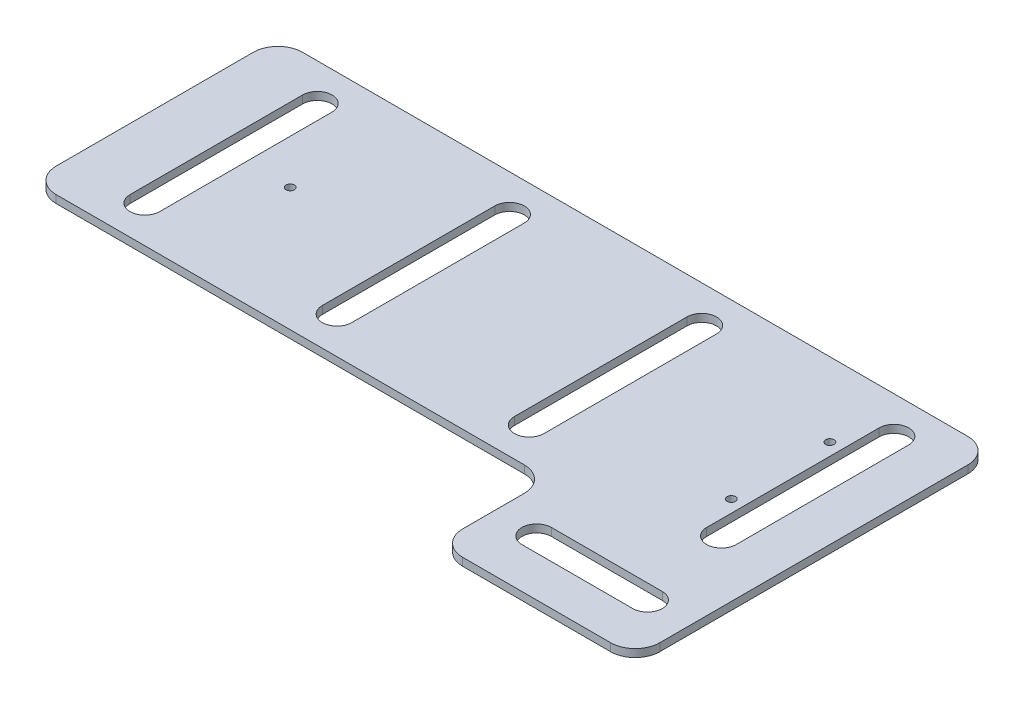
from build123d import *

# Parameters (mm, degrees)
BOSS_EXTRUDE1_DEPTH = 3.175
FILLET1_R           = 10
STANDOFF_HOLES_D    = 3.4
CUT_EXTRUDE1_DEPTH  = 3.175


with BuildPart() as part:
    # Sketch1 → Boss-Extrude1 (new body)
    with BuildSketch(Plane(origin=(0, 0, 0), x_dir=(1, 0, 0), z_dir=(0, 1, 0))):
        Polygon((-37.5, -50), (-145, -50), (-145, 50), (145, 50), (145, -50), (145, -95), (65, -95), (65, -50), (37.5, -50), align=None)
    extrude(amount=BOSS_EXTRUDE1_DEPTH)

    # Fillet1
    fillet1_edges = [part.edges().sort_by_distance(p)[0] for p in [
        (-145, 1.5875, 50),
        (-145, 1.5875, -50),
        (145, 1.5875, -50),
        (145, 1.5875, 95),
        (65, 1.5875, 95),
        (65, 1.5875, 50),
    ]]
    fillet(fillet1_edges, radius=FILLET1_R)

    # standoff holes (through all)
    with Locations(Plane(origin=(0, 3.175, 0), x_dir=(1, 0, 0), z_dir=(0, 1, 0))):
        with Locations((-90, 0), (109, 20), (109, -20)):
            Hole(STANDOFF_HOLES_D / 2)

    # Sketch6 → Cut-Extrude1 (cut)
    with BuildSketch(Plane(origin=(0, 3.175, 0), x_dir=(1, 0, 0), z_dir=(0, 1, 0))):
        with BuildLine():
            Line((-108, 35), (-108, -35))
            ThreePointArc((-108, -35), (-114, -41), (-120, -35))
            Line((-120, -35), (-120, 35))
            ThreePointArc((-120, 35), (-114, 41), (-108, 35))
        make_face()
        with BuildLine():
            Line((-30, 35), (-30, -35))
            ThreePointArc((-30, -35), (-36, -41), (-42, -35))
            Line((-42, -35), (-42, 35))
            ThreePointArc((-42, 35), (-36, 41), (-30, 35))
        make_face()
        with BuildLine():
            Line((48, 35), (48, -35))
            ThreePointArc((48, -35), (42, -41), (36, -35))
            Line((36, -35), (36, 35))
            ThreePointArc((36, 35), (42, 41), (48, 35))
        make_face()
        with BuildLine():
            Line((126, 35), (126, -35))
            ThreePointArc((126, -35), (120, -41), (114, -35))
            Line((114, -35), (114, 35))
            ThreePointArc((114, 35), (120, 41), (126, 35))
        make_face()
        with BuildLine():
            Line((82.5, -66.5), (127.5, -66.5))
            ThreePointArc((127.5, -66.5), (133.5, -72.5), (127.5, -78.5))
            Line((127.5, -78.5), (82.5, -78.5))
            ThreePointArc((82.5, -78.5), (76.5, -72.5), (82.5, -66.5))
        make_face()
    extrude(amount=-CUT_EXTRUDE1_DEPTH, mode=Mode.SUBTRACT)


solid = part.part
